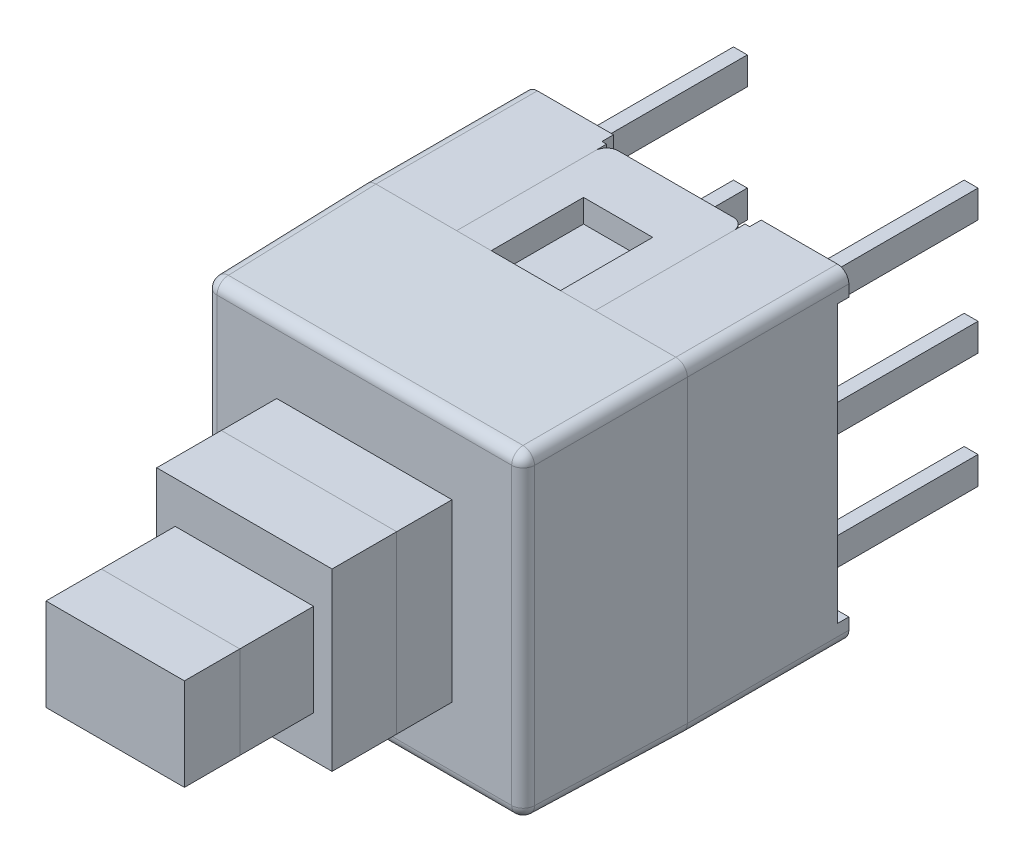
from build123d import *

# Parameters (mm, degrees)
ESQUISSE1_W             = 7
ESQUISSE1_H             = 7
BOSS_EXTRU_1_DEPTH      = 3.5
ENL_V_MAT_EXTRU_1_DEPTH = 0.25
ESQUISSE3_W             = 3
ESQUISSE3_H             = 3.25
ENL_V_MAT_EXTRU_2_DEPTH = 0.5
ENL_V_START             = -7
ESQUISSE3_2_W           = 3
ESQUISSE3_2_H           = 3.25
ENL_V_MAT_EXTRU_3_DEPTH = 0.5
ESQUISSE4_W             = 7
ESQUISSE4_H             = 7
BOSS_EXTRU_2_DEPTH      = 3.5
BOSS_EXTRU_2_TAPER      = 1
ESQUISSE5_W             = 3
ESQUISSE5_H             = 0.5
BOSS_EXTRU_3_DEPTH      = 3.25
ESQUISSE8_W             = 1.5
ESQUISSE8_H             = 2
ENL_V_MAT_EXTRU_4_DEPTH = 4.5
ESQUISSE8_3_W           = 0.6
ESQUISSE8_3_H           = 2
ENL_V_MAT_EXTRU_5_DEPTH = 4.5
CONG_1_R                = 0.25
CONG_2_R                = 0.25
CONG_3_R                = 0.25
CONG_4_R                = 0.25
ESQUISSE6_W             = 3.8
ESQUISSE6_H             = 3.8
BOSS_EXTRU_4_DEPTH      = 1.2
BOSS_EXTRU_5_START      = 1.2
ESQUISSE6_3_W           = 3.8
ESQUISSE6_3_H           = 3.8
BOSS_EXTRU_5_DEPTH      = 1.4
ESQUISSE7_W             = 3
ESQUISSE7_H             = 2
BOSS_EXTRU_6_DEPTH      = 1.6
BOSS_EXTRU_6_DEPTH_BACK = 2.6
BOSS_EXTRU_7_START      = 1.6
ESQUISSE7_2_W           = 3
ESQUISSE7_2_H           = 2
BOSS_EXTRU_7_DEPTH      = 1.2
ESQUISSE9_W             = 0.3
ESQUISSE9_H             = 0.6
BOSS_EXTRU_8_DEPTH      = 3.9
BOSS_EXTRU_8_2_DEPTH    = 3.9
BOSS_EXTRU_8_3_DEPTH    = 3.9
BOSS_EXTRU_8_4_DEPTH    = 3.9
BOSS_EXTRU_8_5_DEPTH    = 3.9
BOSS_EXTRU_8_6_DEPTH    = 3.9


with BuildPart() as part:
    # Esquisse1 → Boss.-Extru.1 (new body)
    with BuildSketch(Plane.XY):
        Rectangle(ESQUISSE1_W, ESQUISSE1_H)
    extrude(amount=BOSS_EXTRU_1_DEPTH)

    # Esquisse2 → Enl_v. mat.-Extru.1 (cut)
    with BuildSketch(Plane(origin=(0, 0, 0), x_dir=(-1, 0, 0), z_dir=(0, 0, -1))):
        Polygon((1.6, 3.5), (-1.6, 3.5), (-1.6, 3), (-3.5, 3), (-3.5, -3), (-1.6, -3), (-1.6, -3.5), (1.6, -3.5), (1.6, -3), (3.5, -3), (3.5, 3), (1.6, 3), align=None)
    extrude(amount=-ENL_V_MAT_EXTRU_1_DEPTH, mode=Mode.SUBTRACT)

    # Esquisse3 → Enl_v. mat.-Extru.2 (cut)
    with BuildSketch(Plane(origin=(0, 3.5, 0), x_dir=(1, 0, 0), z_dir=(0, 1, 0))):
        with Locations((0, -1.875)):
            Rectangle(ESQUISSE3_W, ESQUISSE3_H)
    extrude(amount=-ENL_V_MAT_EXTRU_2_DEPTH, mode=Mode.SUBTRACT)

    # Esquisse3_2 → Enl_v. mat.-Extru.3 (cut)
    with BuildSketch(Plane(origin=(0, 3.5, 0), x_dir=(1, 0, 0), z_dir=(0, 1, 0)).offset(ENL_V_START)):
        with Locations((0, -1.875)):
            Rectangle(ESQUISSE3_2_W, ESQUISSE3_2_H)
    extrude(amount=ENL_V_MAT_EXTRU_3_DEPTH, mode=Mode.SUBTRACT)

    # Cong_1
    cong_1_edges = [part.edges().sort_by_distance(p)[0] for p in [
        (3.5, -3.5, 1.75),
        (-3.5, -3.5, 1.75),
        (-3.5, 3.5, 1.75),
        (3.5, 3.5, 1.75),
    ]]
    fillet(cong_1_edges, radius=CONG_1_R)


with BuildPart() as body_2:
    # Esquisse4 → Boss.-Extru.2 (new body)
    with BuildSketch(Plane.XY.offset(3.5)):
        Rectangle(ESQUISSE4_W, ESQUISSE4_H)
    extrude(amount=BOSS_EXTRU_2_DEPTH, taper=BOSS_EXTRU_2_TAPER)

    # Esquisse5 → Boss.-Extru.3 (add)
    with BuildSketch(Plane(origin=(0, 0, 3.5), x_dir=(-1, 0, 0), z_dir=(0, 0, -1))):
        with Locations((0, 3.25)):
            Rectangle(ESQUISSE5_W, ESQUISSE5_H)
        with Locations((0, -3.25)):
            Rectangle(ESQUISSE5_W, ESQUISSE5_H)
    extrude(amount=BOSS_EXTRU_3_DEPTH)

    # Esquisse8 → Enl_v. mat.-Extru.4 (cut, through all)
    with BuildSketch(Plane(origin=(0, 0, 0), x_dir=(1, 0, 0), z_dir=(0, 1, 0))):
        with Locations((0, -2.5)):
            Rectangle(ESQUISSE8_W, ESQUISSE8_H)
    extrude(amount=ENL_V_MAT_EXTRU_4_DEPTH, mode=Mode.SUBTRACT)

    # Esquisse8_3 → Enl_v. mat.-Extru.5 (cut, through all)
    with BuildSketch(Plane(origin=(0, 0, 0), x_dir=(1, 0, 0), z_dir=(0, 1, 0))):
        with Locations((0.45, -2.5)):
            Rectangle(ESQUISSE8_3_W, ESQUISSE8_3_H)
        with Locations((-0.45, -2.5)):
            Rectangle(ESQUISSE8_3_W, ESQUISSE8_3_H)
    extrude(amount=-ENL_V_MAT_EXTRU_5_DEPTH, mode=Mode.SUBTRACT)

    # Cong_2
    cong_2_edges = [body_2.edges().sort_by_distance(p)[0] for p in [
        (-3.469453636, 3.469453636, 5.25),
        (3.469453636, 3.469453636, 5.25),
        (3.469453636, -3.469453636, 5.25),
        (-3.469453636, -3.469453636, 5.25),
    ]]
    fillet(cong_2_edges, radius=CONG_2_R)

    # Cong_3
    cong_3_edges = [body_2.edges().sort_by_distance(p)[0] for p in [
        (0, 3.438907273, 7),
        (3.438907273, 0, 7),
        (-3.438907273, 0, 7),
        (0, -3.438907273, 7),
        (-3.365699738, 3.365699738, 7),
        (-3.365699738, -3.365699738, 7),
        (3.365699738, -3.365699738, 7),
        (3.365699738, 3.365699738, 7),
    ]]
    fillet(cong_3_edges, radius=CONG_3_R)

    # Cong_4
    cong_4_edges = [body_2.edges().sort_by_distance(p)[0] for p in [
        (1.5, 3.25, 0.25),
        (-1.5, 3.25, 0.25),
        (1.5, -3.25, 0.25),
        (-1.5, -3.25, 0.25),
    ]]
    fillet(cong_4_edges, radius=CONG_4_R)


with BuildPart() as body_3:
    # Esquisse6 → Boss.-Extru.4 (new body)
    with BuildSketch(Plane.XY.offset(7)):
        Rectangle(ESQUISSE6_W, ESQUISSE6_H)
    extrude(amount=BOSS_EXTRU_4_DEPTH)


with BuildPart() as body_4:
    # Esquisse6_3 → Boss.-Extru.5 (new body)
    with BuildSketch(Plane.XY.offset(7).offset(BOSS_EXTRU_5_START)):
        Rectangle(ESQUISSE6_3_W, ESQUISSE6_3_H)
    extrude(amount=BOSS_EXTRU_5_DEPTH)


with BuildPart() as body_5:
    # Esquisse7 → Boss.-Extru.6 (new body, two sides)
    with BuildSketch(Plane.XY.offset(9.6)) as boss_extru_6_sk:
        Rectangle(ESQUISSE7_W, ESQUISSE7_H)
    extrude(amount=BOSS_EXTRU_6_DEPTH)
    extrude(boss_extru_6_sk.sketch, amount=-BOSS_EXTRU_6_DEPTH_BACK)


with BuildPart() as body_6:
    # Esquisse7_2 → Boss.-Extru.7 (new body)
    with BuildSketch(Plane.XY.offset(9.6).offset(BOSS_EXTRU_7_START)):
        Rectangle(ESQUISSE7_2_W, ESQUISSE7_2_H)
    extrude(amount=BOSS_EXTRU_7_DEPTH)


with BuildPart() as body_7:
    # Esquisse9 → Boss.-Extru.8 (new body)
    with BuildSketch(Plane(origin=(0, 0, 0.25), x_dir=(-1, 0, 0), z_dir=(0, 0, -1))):
        with Locations((2.5, -2.5)):
            Rectangle(ESQUISSE9_W, ESQUISSE9_H)
    extrude(amount=BOSS_EXTRU_8_DEPTH)


with BuildPart() as body_8:
    # Esquisse9 → Boss.-Extru.8 2 (new body)
    with BuildSketch(Plane(origin=(0, 0, 0.25), x_dir=(-1, 0, 0), z_dir=(0, 0, -1))):
        with Locations((2.5, 0)):
            Rectangle(ESQUISSE9_W, ESQUISSE9_H)
    extrude(amount=BOSS_EXTRU_8_2_DEPTH)


with BuildPart() as body_9:
    # Esquisse9 → Boss.-Extru.8 3 (new body)
    with BuildSketch(Plane(origin=(0, 0, 0.25), x_dir=(-1, 0, 0), z_dir=(0, 0, -1))):
        with Locations((2.5, 2.5)):
            Rectangle(ESQUISSE9_W, ESQUISSE9_H)
    extrude(amount=BOSS_EXTRU_8_3_DEPTH)


with BuildPart() as body_10:
    # Esquisse9 → Boss.-Extru.8 4 (new body)
    with BuildSketch(Plane(origin=(0, 0, 0.25), x_dir=(-1, 0, 0), z_dir=(0, 0, -1))):
        with Locations((-2.5, 2.5)):
            Rectangle(ESQUISSE9_W, ESQUISSE9_H)
    extrude(amount=BOSS_EXTRU_8_4_DEPTH)


with BuildPart() as body_11:
    # Esquisse9 → Boss.-Extru.8 5 (new body)
    with BuildSketch(Plane(origin=(0, 0, 0.25), x_dir=(-1, 0, 0), z_dir=(0, 0, -1))):
        with Locations((-2.5, 0)):
            Rectangle(ESQUISSE9_W, ESQUISSE9_H)
    extrude(amount=BOSS_EXTRU_8_5_DEPTH)


with BuildPart() as body_12:
    # Esquisse9 → Boss.-Extru.8 6 (new body)
    with BuildSketch(Plane(origin=(0, 0, 0.25), x_dir=(-1, 0, 0), z_dir=(0, 0, -1))):
        with Locations((-2.5, -2.5)):
            Rectangle(ESQUISSE9_W, ESQUISSE9_H)
    extrude(amount=BOSS_EXTRU_8_6_DEPTH)


solid = Compound([part.part, body_2.part, body_3.part, body_4.part, body_5.part, body_6.part, body_7.part, body_8.part, body_9.part, body_10.part, body_11.part, body_12.part])
